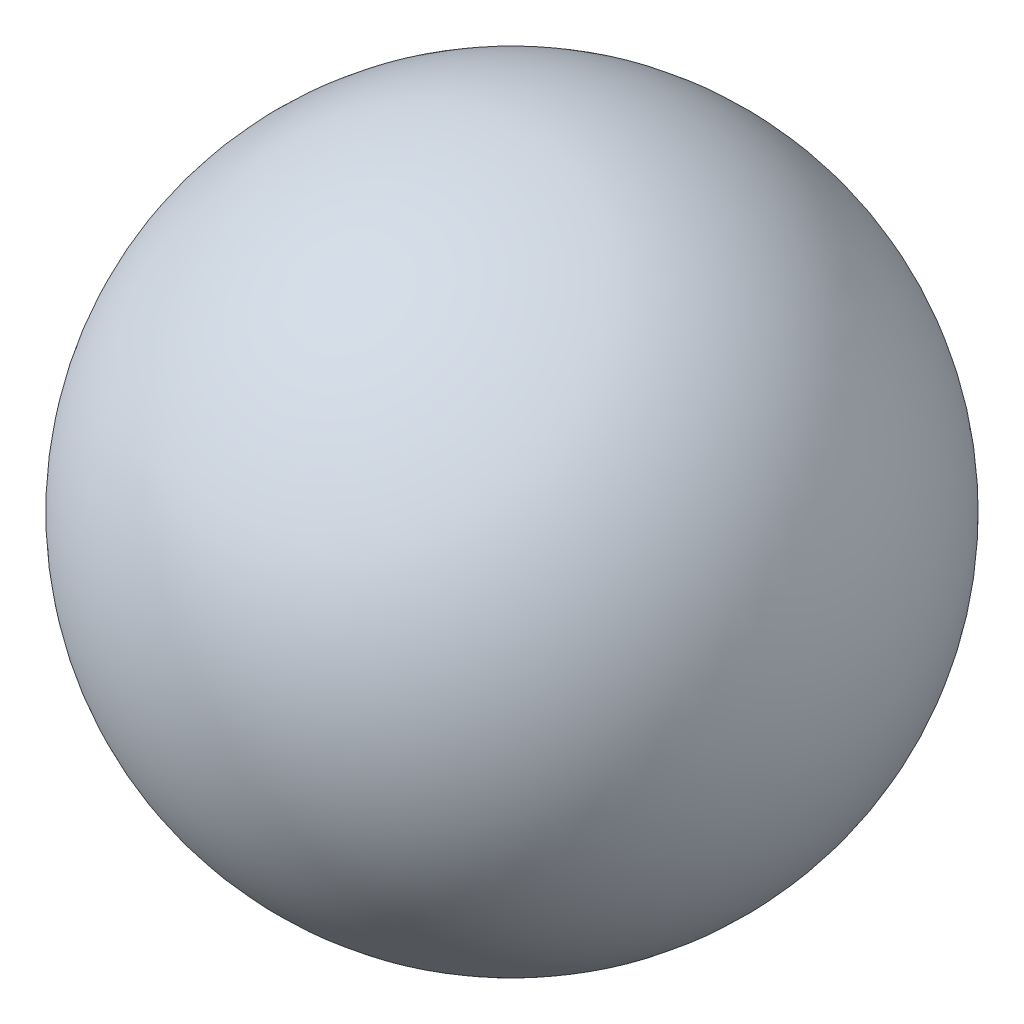
from build123d import *


with BuildPart() as part:
    # 草图1 one side → 旋转5 (revolve)
    with BuildSketch(Plane.XY):
        with BuildLine():
            Line((0, -2.5), (0, 2.5))
            ThreePointArc((0, 2.5), (-2.5, 0), (0, -2.5))
        make_face()
    revolve(axis=Axis((0, -2.878220792, 0), (0, 1, 0)))


solid = part.part
